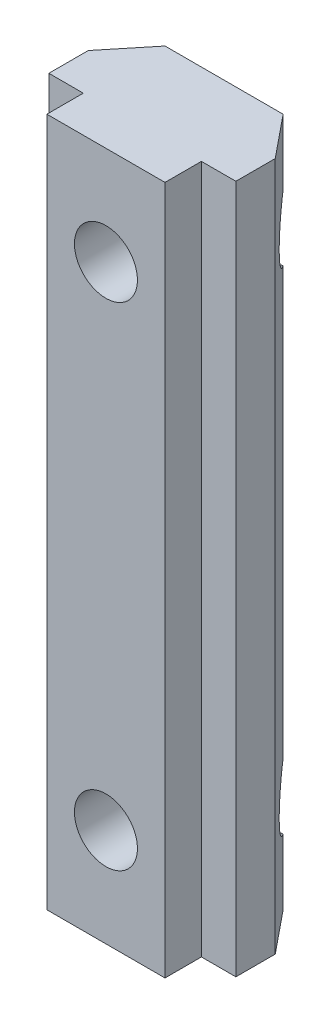
from build123d import *

# Parameters (mm, degrees)
EXTRUDE1_DEPTH             = 35
EXTRUDE2_REACH             = 37.827
SKETCH2_R                  = 1.6
SKETCH_R                   = 1.6
EXTRUDE3_DEPTH             = 3.5
EXTRUDE4_REACH             = 38.934
EXTRUDE4_DIRECTION_2_REACH = 38.934


with BuildPart() as part:
    # Sketch1 → Extrude1 (new body)
    with BuildSketch(Plane(origin=(0, 0, 0), x_dir=(1, 0, 0), z_dir=(0, 1, 0))):
        Polygon((-3, 2.978553588), (3, 2.978553588), (3, 4.828553588), (4.75, 4.828553588), (4.75, 6.828553588), (3, 8.978553588), (-3, 8.978553588), (-4.75, 6.828553588), (-4.75, 4.828553588), (-3, 4.828553588), align=None)
    extrude(amount=EXTRUDE1_DEPTH)

    # Sketch2 → Extrude2 (cut, up to next)
    with BuildSketch(Plane(origin=(0, 0, -8.978553588), x_dir=(-1, 0, 0), z_dir=(0, 0, -1)), mode=Mode.PRIVATE) as extrude2_sk1:
        with Locations((0, 30)):
            Circle(SKETCH2_R)
    extrude2_tool1 = extrude(extrude2_sk1.sketch, amount=-EXTRUDE2_REACH, mode=Mode.PRIVATE) & part.part
    # Sketch2 → Extrude2 (cut, up to next)
    with BuildSketch(Plane(origin=(0, 0, -8.978553588), x_dir=(-1, 0, 0), z_dir=(0, 0, -1)), mode=Mode.PRIVATE) as extrude2_sk2:
        with Locations((0, 5)):
            Circle(SKETCH2_R)
    extrude2_tool2 = extrude(extrude2_sk2.sketch, amount=-EXTRUDE2_REACH, mode=Mode.PRIVATE) & part.part
    add(extrude2_tool1.solids().sort_by_distance((0, 30, -8.978554))[0], mode=Mode.SUBTRACT)
    add(extrude2_tool2.solids().sort_by_distance((0, 5, -8.978554))[0], mode=Mode.SUBTRACT)

    # Sketch → Extrude3 (cut)
    # profile 1 of 2: a face of its own
    with BuildSketch(Plane(origin=(0, 0, -8.978553588), x_dir=(-1, 0, 0), z_dir=(0, 0, -1))):
        Polygon((0, 33.348631561), (-2.9, 31.674315781), (-2.9, 28.325684219), (0, 26.651368439), (2.9, 28.325684219), (2.9, 31.674315781), align=None)
        with Locations((0, 30)):
            Circle(SKETCH_R, mode=Mode.SUBTRACT)
    # profile 2 of 2: a face of its own
    with BuildSketch(Plane(origin=(0, 0, -8.978553588), x_dir=(-1, 0, 0), z_dir=(0, 0, -1))):
        Polygon((2.9, 3.325684219), (0, 1.651368439), (-2.9, 3.325684219), (-2.9, 6.674315781), (0, 8.348631561), (2.9, 6.674315781), align=None)
        with Locations((0, 5)):
            Circle(SKETCH_R, mode=Mode.SUBTRACT)
    extrude(amount=-EXTRUDE3_DEPTH, mode=Mode.SUBTRACT)

    # Sketch3 → Extrude4 (cut, up to next)
    with BuildSketch(Plane(origin=(-2.9, 0, 0), x_dir=(0, 0, -1), z_dir=(1, 0, 0)), mode=Mode.PRIVATE) as extrude4_sk1:
        with BuildLine():
            Line((8.978553588, 31.674315781), (8.978553588, 28.325684219))
            ThreePointArc((8.978553588, 28.325684219), (7.912621815, 30), (8.978553588, 31.674315781))
        make_face()
    extrude4_tool1 = extrude(extrude4_sk1.sketch, amount=-EXTRUDE4_REACH, mode=Mode.PRIVATE) & part.part
    extrude4 = extrude4_tool1.solids().sort_by_distance((-2.9, 30, -8.539494))[0]
    add(extrude4, mode=Mode.SUBTRACT)

    # Sketch3 → Extrude4 direction 2 (cut, up to next)
    with BuildSketch(Plane(origin=(-2.9, 0, 0), x_dir=(0, 0, -1), z_dir=(1, 0, 0)), mode=Mode.PRIVATE) as extrude4_direction_2_sk1:
        with BuildLine():
            Line((8.978553588, 31.674315781), (8.978553588, 28.325684219))
            ThreePointArc((8.978553588, 28.325684219), (7.912621815, 30), (8.978553588, 31.674315781))
        make_face()
    extrude4_direction_2_tool1 = extrude(extrude4_direction_2_sk1.sketch, amount=EXTRUDE4_DIRECTION_2_REACH, mode=Mode.PRIVATE) & part.part
    extrude4_direction_2 = extrude4_direction_2_tool1.solids().sort_by_distance((-2.9, 30, -8.539494))[0]
    add(extrude4_direction_2, mode=Mode.SUBTRACT)

    # Mirror1: Extrude4, Extrude4 direction 2 across plane
    add(extrude4.mirror(Plane.ZX.offset(17.5)), mode=Mode.SUBTRACT)
    add(extrude4_direction_2.mirror(Plane.ZX.offset(17.5)), mode=Mode.SUBTRACT)


solid = part.part
